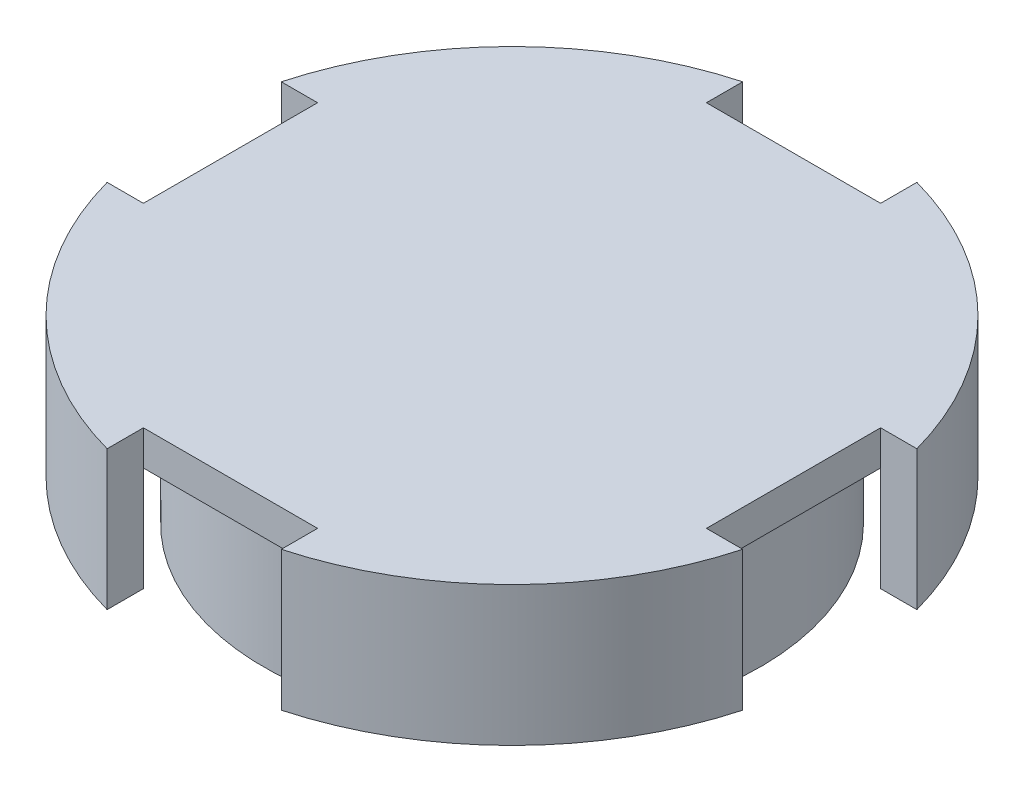
from build123d import *

# Parameters (mm, degrees)
SKETCH1_R                = 1.55
BOSS_EXTRUDE1_DEPTH      = 11.5
SKETCH1_3_R              = 1.55
BOSS_EXTRUDE2_DEPTH      = 11.5
BOSS_EXTRUDE2_DEPTH_BACK = 5
BOSS_EXTRUDE3_START      = 11.5
SKETCH2_R                = 21.4
SKETCH2_R_2              = 18.4
BOSS_EXTRUDE3_DEPTH      = 4
BOSS_EXTRUDE4_START      = 15.5
SKETCH2_3_R              = 21.4
BOSS_EXTRUDE4_DEPTH      = 3
BOSS_EXTRUDE5_START      = 15.5
BOSS_EXTRUDE5_DEPTH      = 12


with BuildPart() as part:
    # Sketch1 → Boss-Extrude1 (new body)
    with BuildSketch(Plane(origin=(0, 0, 0), x_dir=(1, 0, 0), z_dir=(0, 1, 0))):
        with BuildLine():
            Line((2.05, 16.301584448), (-2.05, 16.301584448))
            Line((-2.05, 16.301584448), (-2.05, 21.301584448))
            ThreePointArc((-2.05, 21.301584448), (0, -21.4), (2.05, 21.301584448))
            Line((2.05, 21.301584448), (2.05, 16.301584448))
        make_face()
        with Locations(Location((-8.6, 0, 0), (0, 0, 270))):
            Circle(SKETCH1_R, mode=Mode.SUBTRACT)
        with Locations(Location((8.6, 0, 0), (0, 0, 270))):
            Circle(SKETCH1_R, mode=Mode.SUBTRACT)
    extrude(amount=BOSS_EXTRUDE1_DEPTH)

    # Sketch1_3 → Boss-Extrude2 (add, two sides)
    with BuildSketch(Plane(origin=(0, 0, 0), x_dir=(1, 0, 0), z_dir=(0, 1, 0))) as boss_extrude2_sk:
        with Locations(Location((-8.6, 0, 0), (0, 0, 270))):
            Circle(SKETCH1_3_R)
        with Locations(Location((8.6, 0, 0), (0, 0, 270))):
            Circle(SKETCH1_3_R)
    extrude(amount=BOSS_EXTRUDE2_DEPTH)
    extrude(boss_extrude2_sk.sketch, amount=-BOSS_EXTRUDE2_DEPTH_BACK)

    # Sketch2 → Boss-Extrude3 (add)
    with BuildSketch(Plane(origin=(0, 0, 0), x_dir=(1, 0, 0), z_dir=(0, 1, 0)).offset(BOSS_EXTRUDE3_START)):
        with Locations(Location((0, 0, 0), (0, 0, 84.502956314))):
            Circle(SKETCH2_R)
        Circle(SKETCH2_R_2, mode=Mode.SUBTRACT)
        Circle(SKETCH2_R_2)
    extrude(amount=BOSS_EXTRUDE3_DEPTH)

    # Sketch2_3 → Boss-Extrude4 (add)
    with BuildSketch(Plane(origin=(0, 0, 0), x_dir=(1, 0, 0), z_dir=(0, 1, 0)).offset(BOSS_EXTRUDE4_START)):
        with BuildLine():
            Line((7.5, 24.241299986), (-7.5, 24.241299986))
            ThreePointArc((-7.5, 24.241299986), (-17.942834573, 17.942834573), (-24.241299986, 7.5))
            Line((-24.241299986, 7.5), (-24.241299986, -7.5))
            ThreePointArc((-24.241299986, -7.5), (-17.942834573, -17.942834573), (-7.5, -24.241299986))
            Line((-7.5, -24.241299986), (7.5, -24.241299986))
            ThreePointArc((7.5, -24.241299986), (17.942834573, -17.942834573), (24.241299986, -7.5))
            Line((24.241299986, -7.5), (24.241299986, 7.5))
            ThreePointArc((24.241299986, 7.5), (17.942834573, 17.942834573), (7.5, 24.241299986))
        make_face()
        with Locations(Location((0, 0, 0), (0, 0, 84.502956314))):
            Circle(SKETCH2_3_R, mode=Mode.SUBTRACT)
    extrude(amount=-BOSS_EXTRUDE4_DEPTH)

    # Sketch2_4 → Boss-Extrude5 (add)
    with BuildSketch(Plane(origin=(0, 0, 0), x_dir=(1, 0, 0), z_dir=(0, 1, 0)).offset(BOSS_EXTRUDE5_START)):
        with BuildLine():
            Line((-7.5, 24.241299986), (-7.5, 27.365866056))
            ThreePointArc((-7.5, 27.365866056), (-20.064154916, 20.064154916), (-27.365866056, 7.5))
            Line((-27.365866056, 7.5), (-24.241299986, 7.5))
            ThreePointArc((-24.241299986, 7.5), (-17.942834573, 17.942834573), (-7.5, 24.241299986))
        make_face()
        with BuildLine():
            ThreePointArc((27.365866056, 7.5), (20.064154916, 20.064154916), (7.5, 27.365866056))
            Line((7.5, 27.365866056), (7.5, 24.241299986))
            ThreePointArc((7.5, 24.241299986), (17.942834573, 17.942834573), (24.241299986, 7.5))
            Line((24.241299986, 7.5), (27.365866056, 7.5))
        make_face()
        with BuildLine():
            Line((-24.241299986, -7.5), (-27.365866056, -7.5))
            ThreePointArc((-27.365866056, -7.5), (-20.064154916, -20.064154916), (-7.5, -27.365866056))
            Line((-7.5, -27.365866056), (-7.5, -24.241299986))
            ThreePointArc((-7.5, -24.241299986), (-17.942834573, -17.942834573), (-24.241299986, -7.5))
        make_face()
        with BuildLine():
            Line((27.365866056, -7.5), (24.241299986, -7.5))
            ThreePointArc((24.241299986, -7.5), (17.942834573, -17.942834573), (7.5, -24.241299986))
            Line((7.5, -24.241299986), (7.5, -27.365866056))
            ThreePointArc((7.5, -27.365866056), (20.064154916, -20.064154916), (27.365866056, -7.5))
        make_face()
    extrude(amount=-BOSS_EXTRUDE5_DEPTH)


solid = part.part
